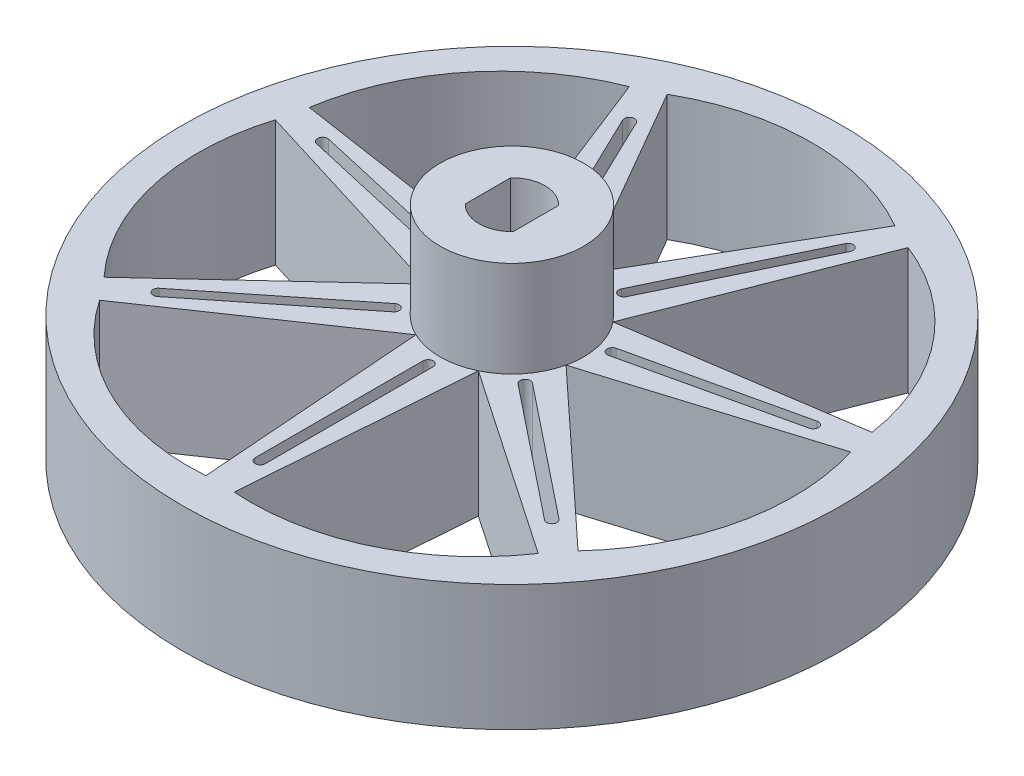
from build123d import *

# Parameters (mm, degrees)
SKETCH2_R           = 6
BOSS_EXTRUDE1_DEPTH = 8
SKETCH3_R           = 27.5
SKETCH3_R_2         = 1.375
BOSS_EXTRUDE2_DEPTH = 10.5
SKETCH4_R           = 3
CUT_EXTRUDE1_DEPTH  = 9.5
CUT_EXTRUDE2_REACH  = 12.5


with BuildPart() as part:
    # Sketch2 → Boss-Extrude1 (new body)
    with BuildSketch(Plane(origin=(0, 0, 0), x_dir=(1, 0, 0), z_dir=(0, 1, 0))):
        Circle(SKETCH2_R)
        with BuildLine():
            ThreePointArc((-2, -1.887458609), (0, -2.75), (2, -1.887458609))
            Line((2, -1.887458609), (2, 1.887458609))
            ThreePointArc((2, 1.887458609), (0, 2.75), (-2, 1.887458609))
            Line((-2, 1.887458609), (-2, -1.887458609))
        make_face(mode=Mode.SUBTRACT)
    extrude(amount=BOSS_EXTRUDE1_DEPTH)

    # Sketch3 → Boss-Extrude2 (add)
    with BuildSketch(Plane(origin=(0, 0, 0), x_dir=(1, 0, 0), z_dir=(0, 1, 0))):
        Circle(SKETCH3_R)
        Circle(SKETCH3_R_2, mode=Mode.SUBTRACT)
        with BuildLine():
            Line((0, 6), (9.5, 22.454482672))
            ThreePointArc((9.5, 22.454482672), (0, 25), (-9.5, 22.454482672))
            Line((-9.5, 22.454482672), (0, 6))
        make_face(mode=Mode.SUBTRACT)
        with BuildLine():
            Line((4.690988895, 3.740938811), (11.632468358, 21.427540035))
            ThreePointArc((11.632468358, 21.427540035), (19.545787062, 15.587245046), (23.478774593, 6.572741869))
            Line((23.478774593, 6.572741869), (4.690988895, 3.740938811))
        make_face(mode=Mode.SUBTRACT)
        with BuildLine():
            Line((5.849567473, -1.335125604), (24.005450783, 4.26522271))
            ThreePointArc((24.005450783, 4.26522271), (24.373197805, -5.563023349), (19.777553038, -14.258407621))
            Line((19.777553038, -14.258407621), (5.849567473, -1.335125604))
        make_face(mode=Mode.SUBTRACT)
        with BuildLine():
            Line((2.603302435, -5.405813207), (18.301839147, -16.108894311))
            ThreePointArc((18.301839147, -16.108894311), (10.847093478, -22.524221698), (1.183430657, -24.352685354))
            Line((1.183430657, -24.352685354), (2.603302435, -5.405813207))
        make_face(mode=Mode.SUBTRACT)
        with BuildLine():
            Line((-2.603302435, -5.405813207), (-1.183430657, -24.352685354))
            ThreePointArc((-1.183430657, -24.352685354), (-10.847093478, -22.524221698), (-18.301839147, -16.108894311))
            Line((-18.301839147, -16.108894311), (-2.603302435, -5.405813207))
        make_face(mode=Mode.SUBTRACT)
        with BuildLine():
            Line((-5.849567473, -1.335125604), (-19.777553038, -14.258407621))
            ThreePointArc((-19.777553038, -14.258407621), (-24.373197805, -5.563023349), (-24.005450783, 4.26522271))
            Line((-24.005450783, 4.26522271), (-5.849567473, -1.335125604))
        make_face(mode=Mode.SUBTRACT)
        with BuildLine():
            Line((-4.690988895, 3.740938811), (-23.478774593, 6.572741868))
            ThreePointArc((-23.478774593, 6.572741868), (-19.545787062, 15.587245046), (-11.632468358, 21.427540035))
            Line((-11.632468358, 21.427540035), (-4.690988895, 3.740938811))
        make_face(mode=Mode.SUBTRACT)
    extrude(amount=-BOSS_EXTRUDE2_DEPTH)

    # Sketch4 → Cut-Extrude1 (cut)
    with BuildSketch(Plane(origin=(0, -10.5, 0), x_dir=(-1, 0, 0), z_dir=(0, -1, 0))):
        Circle(SKETCH4_R)
    extrude(amount=-CUT_EXTRUDE1_DEPTH, mode=Mode.SUBTRACT)

    # Sketch5 → Cut-Extrude2 (cut, up to next)
    with BuildSketch(Plane(origin=(0, 0, 0), x_dir=(1, 0, 0), z_dir=(0, 1, 0)), mode=Mode.PRIVATE) as cut_extrude2_sk1:
        with BuildLine():
            ThreePointArc((-5.206364569, -4.698553628), (-5.138695362, -4.097972805), (-5.739276185, -4.030303598))
            Line((-5.739276185, -4.030303598), (-16.68491694, -12.759160824))
            ThreePointArc((-16.68491694, -12.759160824), (-16.752586147, -13.359741647), (-16.152005324, -13.427410854))
            Line((-16.152005324, -13.427410854), (-5.206364569, -4.698553628))
        make_face()
    cut_extrude2_tool1 = extrude(cut_extrude2_sk1.sketch, amount=-CUT_EXTRUDE2_REACH, mode=Mode.PRIVATE) & part.part
    add(cut_extrude2_tool1.solids().sort_by_distance((-10.945641, 0, 8.728857))[0], mode=Mode.SUBTRACT)
    # Sketch5 → Cut-Extrude2 (cut, up to next)
    with BuildSketch(Plane(origin=(0, 0, 0), x_dir=(1, 0, 0), z_dir=(0, 1, 0)), mode=Mode.PRIVATE) as cut_extrude2_sk2:
        with BuildLine():
            Line((0.427361935, -21), (0.427361935, -7))
            ThreePointArc((0.427361935, -7), (0, -6.572638065), (-0.427361935, -7))
            Line((-0.427361935, -7), (-0.427361935, -21))
            ThreePointArc((-0.427361935, -21), (0, -21.427361935), (0.427361935, -21))
        make_face()
    cut_extrude2_tool2 = extrude(cut_extrude2_sk2.sketch, amount=-CUT_EXTRUDE2_REACH, mode=Mode.PRIVATE) & part.part
    add(cut_extrude2_tool2.solids().sort_by_distance((0, 0, 14))[0], mode=Mode.SUBTRACT)
    # Sketch5 → Cut-Extrude2 (cut, up to next)
    with BuildSketch(Plane(origin=(0, 0, 0), x_dir=(1, 0, 0), z_dir=(0, 1, 0)), mode=Mode.PRIVATE) as cut_extrude2_sk3:
        with BuildLine():
            ThreePointArc((-6.919592362, 1.140999459), (-6.407848306, 1.462549561), (-6.729398408, 1.974293617))
            Line((-6.729398408, 1.974293617), (-20.378389179, 5.089586692))
            ThreePointArc((-20.378389179, 5.089586692), (-20.890133235, 4.76803659), (-20.568583133, 4.256292534))
            Line((-20.568583133, 4.256292534), (-6.919592362, 1.140999459))
        make_face()
    cut_extrude2_tool3 = extrude(cut_extrude2_sk3.sketch, amount=-CUT_EXTRUDE2_REACH, mode=Mode.PRIVATE) & part.part
    add(cut_extrude2_tool3.solids().sort_by_distance((-13.648991, 0, -3.115293))[0], mode=Mode.SUBTRACT)
    # Sketch5 → Cut-Extrude2 (cut, up to next)
    with BuildSketch(Plane(origin=(0, 0, 0), x_dir=(1, 0, 0), z_dir=(0, 1, 0)), mode=Mode.PRIVATE) as cut_extrude2_sk4:
        with BuildLine():
            ThreePointArc((-3.422225972, 6.121356681), (-2.85176078, 5.921742277), (-2.652146375, 6.49220747))
            Line((-2.652146375, 6.49220747), (-8.726518723, 19.10577162))
            ThreePointArc((-8.726518723, 19.10577162), (-9.296983916, 19.305386025), (-9.49659832, 18.734920832))
            Line((-9.49659832, 18.734920832), (-3.422225972, 6.121356681))
        make_face()
    cut_extrude2_tool4 = extrude(cut_extrude2_sk4.sketch, amount=-CUT_EXTRUDE2_REACH, mode=Mode.PRIVATE) & part.part
    add(cut_extrude2_tool4.solids().sort_by_distance((-6.074372, 0, -12.613564))[0], mode=Mode.SUBTRACT)
    # Sketch5 → Cut-Extrude2 (cut, up to next)
    with BuildSketch(Plane(origin=(0, 0, 0), x_dir=(1, 0, 0), z_dir=(0, 1, 0)), mode=Mode.PRIVATE) as cut_extrude2_sk5:
        with BuildLine():
            ThreePointArc((2.652146375, 6.49220747), (2.85176078, 5.921742277), (3.422225972, 6.121356681))
            Line((3.422225972, 6.121356681), (9.49659832, 18.734920832))
            ThreePointArc((9.49659832, 18.734920832), (9.296983916, 19.305386025), (8.726518723, 19.10577162))
            Line((8.726518723, 19.10577162), (2.652146375, 6.49220747))
        make_face()
    cut_extrude2_tool5 = extrude(cut_extrude2_sk5.sketch, amount=-CUT_EXTRUDE2_REACH, mode=Mode.PRIVATE) & part.part
    add(cut_extrude2_tool5.solids().sort_by_distance((6.074372, 0, -12.613564))[0], mode=Mode.SUBTRACT)
    # Sketch5 → Cut-Extrude2 (cut, up to next)
    with BuildSketch(Plane(origin=(0, 0, 0), x_dir=(1, 0, 0), z_dir=(0, 1, 0)), mode=Mode.PRIVATE) as cut_extrude2_sk6:
        with BuildLine():
            ThreePointArc((6.729398408, 1.974293617), (6.407848306, 1.462549561), (6.919592362, 1.140999459))
            Line((6.919592362, 1.140999459), (20.568583133, 4.256292534))
            ThreePointArc((20.568583133, 4.256292534), (20.890133235, 4.76803659), (20.378389179, 5.089586692))
            Line((20.378389179, 5.089586692), (6.729398408, 1.974293617))
        make_face()
    cut_extrude2_tool6 = extrude(cut_extrude2_sk6.sketch, amount=-CUT_EXTRUDE2_REACH, mode=Mode.PRIVATE) & part.part
    add(cut_extrude2_tool6.solids().sort_by_distance((13.648991, 0, -3.115293))[0], mode=Mode.SUBTRACT)
    # Sketch5 → Cut-Extrude2 (cut, up to next)
    with BuildSketch(Plane(origin=(0, 0, 0), x_dir=(1, 0, 0), z_dir=(0, 1, 0)), mode=Mode.PRIVATE) as cut_extrude2_sk7:
        with BuildLine():
            ThreePointArc((5.739276185, -4.030303598), (5.138695362, -4.097972805), (5.206364569, -4.698553628))
            Line((5.206364569, -4.698553628), (16.152005324, -13.427410854))
            ThreePointArc((16.152005324, -13.427410854), (16.752586147, -13.359741647), (16.68491694, -12.759160824))
            Line((16.68491694, -12.759160824), (5.739276185, -4.030303598))
        make_face()
    cut_extrude2_tool7 = extrude(cut_extrude2_sk7.sketch, amount=-CUT_EXTRUDE2_REACH, mode=Mode.PRIVATE) & part.part
    add(cut_extrude2_tool7.solids().sort_by_distance((10.945641, 0, 8.728857))[0], mode=Mode.SUBTRACT)


solid = part.part
